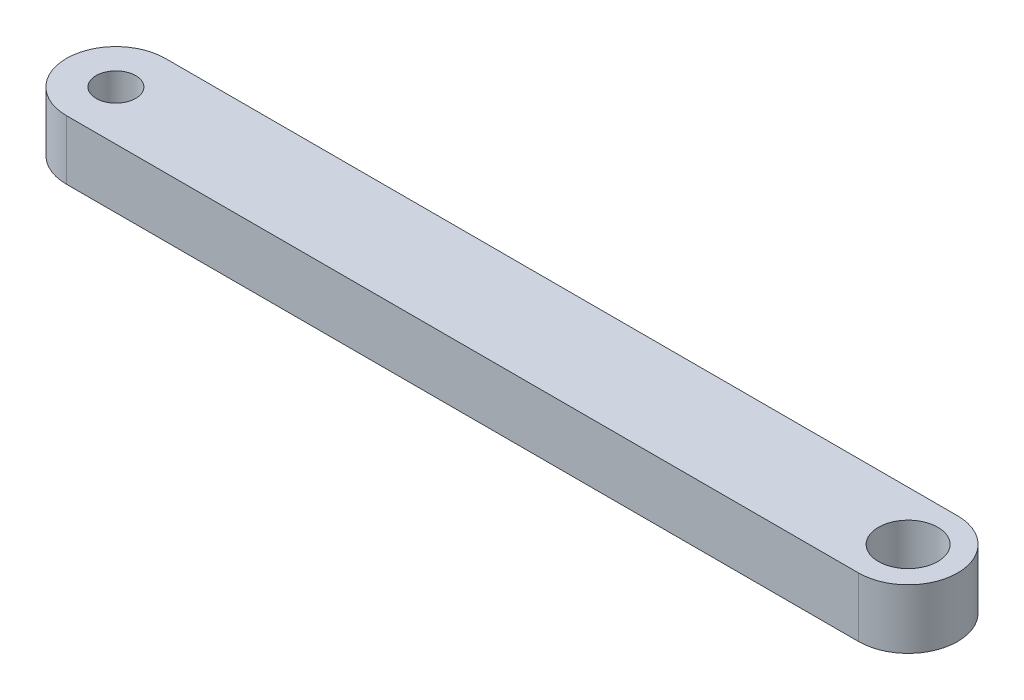
from build123d import *

# Parameters (mm, degrees)
SKETCH1_R           = 1.5
SKETCH1_R_2         = 1
BOSS_EXTRUDE1_DEPTH = 3


with BuildPart() as part:
    # Sketch1 → Boss-Extrude1 (new body)
    with BuildSketch(Plane.XZ):
        with BuildLine():
            Line((31, 2.5), (-9, 2.5))
            ThreePointArc((-9, 2.5), (-11.5, 0), (-9, -2.5))
            Line((-9, -2.5), (31, -2.5))
            ThreePointArc((31, -2.5), (33.5, 0), (31, 2.5))
        make_face()
        with Locations((31, 0)):
            Circle(SKETCH1_R, mode=Mode.SUBTRACT)
        with Locations((-9, 0)):
            Circle(SKETCH1_R_2, mode=Mode.SUBTRACT)
    extrude(amount=-BOSS_EXTRUDE1_DEPTH)


solid = part.part
